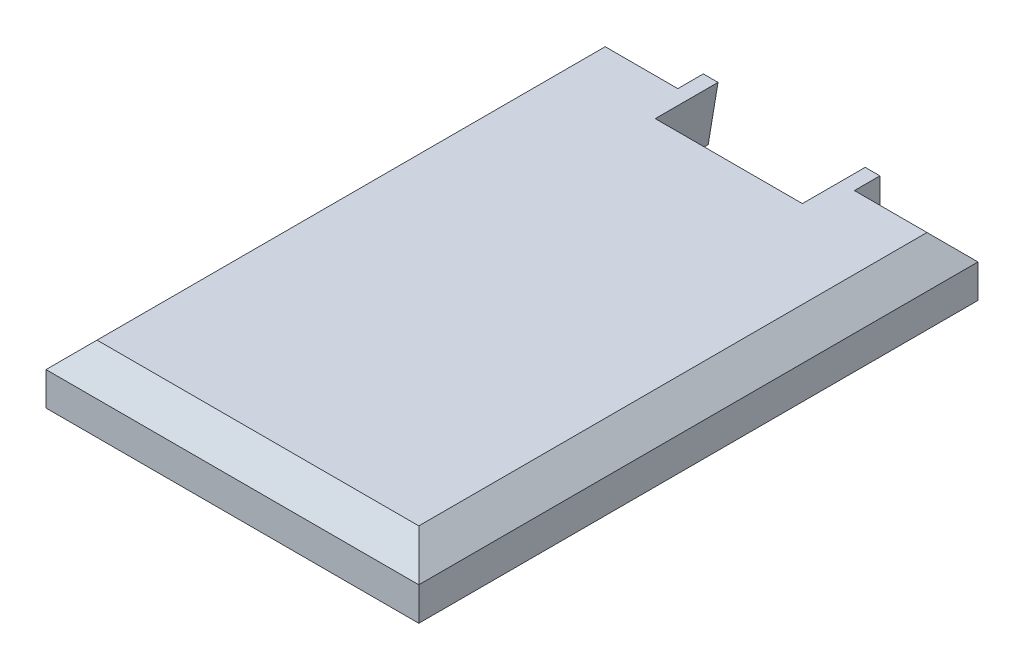
from build123d import *

# Parameters (mm, degrees)
SKETCH1_W           = 190
SKETCH1_H           = 285
BOSS_EXTRUDE1_DEPTH = 30
CUT_EXTRUDE1_DEPTH  = 32
SKETCH4_R           = 1.5
CUT_EXTRUDE2_DEPTH  = 40
CUT_EXTRUDE3_START  = 45
CUT_EXTRUDE3_DEPTH  = 51
CUT_EXTRUDE4_START  = -45
CUT_EXTRUDE4_DEPTH  = 51
CHAMFER1_SIZE       = 13
SKETCH6_R           = 1.5
CUT_EXTRUDE5_DEPTH  = 5


with BuildPart() as part:
    # Sketch1 → Boss-Extrude1 (new body)
    with BuildSketch(Plane(origin=(0, 0, 0), x_dir=(1, 0, 0), z_dir=(0, 1, 0))):
        Rectangle(SKETCH1_W, SKETCH1_H)
    extrude(amount=BOSS_EXTRUDE1_DEPTH)

    # Sketch3 → Cut-Extrude1 (cut)
    with BuildSketch(Plane(origin=(0, 0, -142.5), x_dir=(-1, 0, 0), z_dir=(0, 0, -1))):
        Polygon((-37.5, 30), (37.5, 30), (42.5, 0), (-42.5, 0), align=None)
    extrude(amount=-CUT_EXTRUDE1_DEPTH, mode=Mode.SUBTRACT)

    # Sketch4 → Cut-Extrude2 (cut)
    with BuildSketch(Plane(origin=(0, 0, -110.5), x_dir=(-1, 0, 0), z_dir=(0, 0, -1))):
        with Locations((-25, 14)):
            Circle(SKETCH4_R)
        with Locations(Location((25, 14, 0), (0, 0, 180))):  # turned: the seam where the file's is
            Circle(SKETCH4_R)
    extrude(amount=-CUT_EXTRUDE2_DEPTH, mode=Mode.SUBTRACT)

    # Sketch5 → Cut-Extrude3 (cut, through all)
    with BuildSketch(Plane(origin=(0, 0, 0), x_dir=(0, 0, -1), z_dir=(1, 0, 0)).offset(CUT_EXTRUDE3_START)):
        Polygon((129.5, 30), (142.5, 17), (142.5, 30), align=None)
    extrude(amount=CUT_EXTRUDE3_DEPTH, mode=Mode.SUBTRACT)

    # Sketch5_2 → Cut-Extrude4 (cut, through all)
    with BuildSketch(Plane(origin=(0, 0, 0), x_dir=(0, 0, -1), z_dir=(1, 0, 0)).offset(CUT_EXTRUDE4_START)):
        Polygon((129.5, 30), (142.5, 17), (142.5, 30), align=None)
    extrude(amount=-CUT_EXTRUDE4_DEPTH, mode=Mode.SUBTRACT)

    # Chamfer1
    chamfer1_edges = [part.edges().sort_by_distance(p)[0] for p in [
        (-95, 30, 6.5),
        (0, 30, 142.5),
        (95, 30, 6.5),
    ]]
    chamfer(chamfer1_edges, length=CHAMFER1_SIZE)

    # Sketch6 → Cut-Extrude5 (cut)
    with BuildSketch(Plane.XZ):
        with Locations(Location((-75, 122.5, 0), (0, 0, 270))):  # turned: the seam where the file's is
            Circle(SKETCH6_R)
        with Locations(Location((75, 122.5, 0), (0, 0, 270))):  # turned: the seam where the file's is
            Circle(SKETCH6_R)
        with Locations(Location((-75, -122.5, 0), (0, 0, 270))):  # turned: the seam where the file's is
            Circle(SKETCH6_R)
        with Locations(Location((75, -122.5, 0), (0, 0, 270))):  # turned: the seam where the file's is
            Circle(SKETCH6_R)
    extrude(amount=-CUT_EXTRUDE5_DEPTH, mode=Mode.SUBTRACT)


solid = part.part
